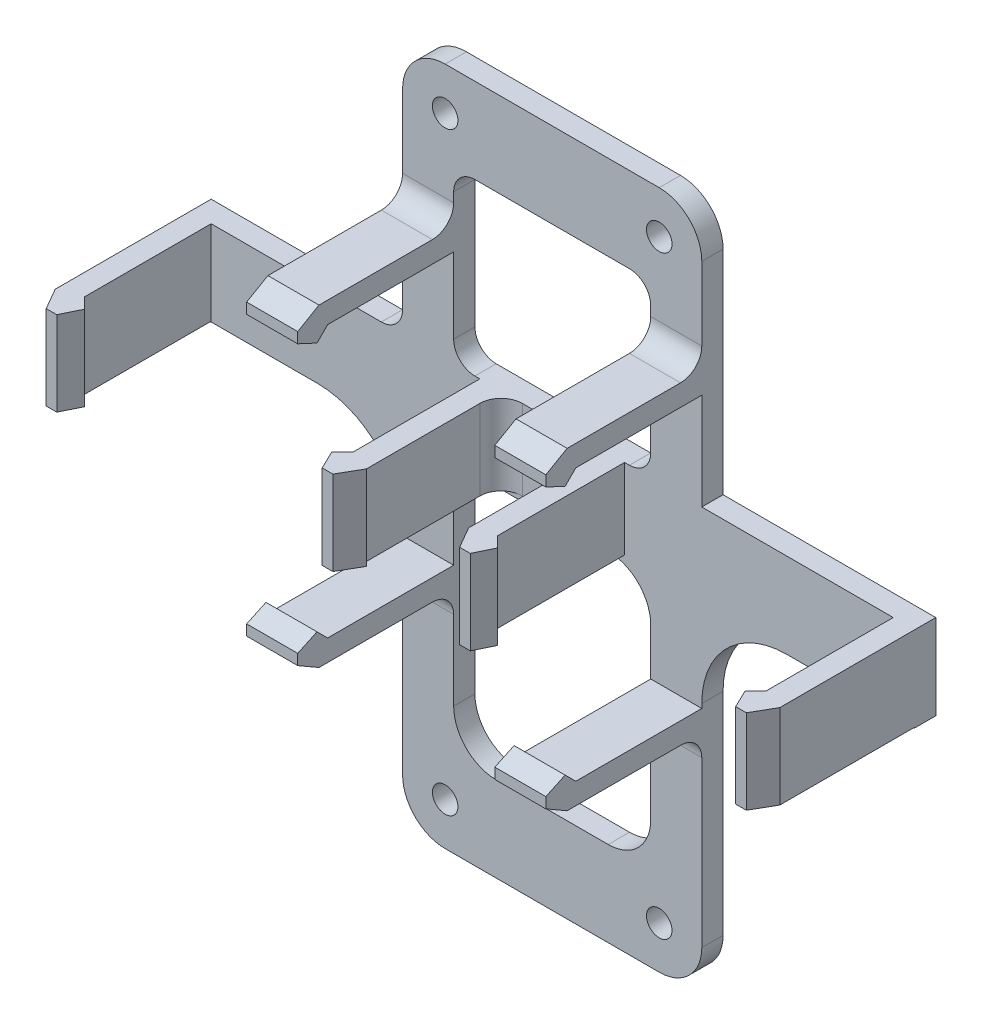
from build123d import *

# Parameters (mm, degrees)
SKETCH1_R           = 1.905
SKETCH1_W           = 29.4132
SKETCH1_H           = 25.4
BOSS_EXTRUDE1_DEPTH = 3.175
SKETCH2_W           = 3.175
SKETCH2_H           = 12.603189316
SKETCH2_H_2         = 11.966378631
SKETCH2_W_2         = 7.62
SKETCH2_H_3         = 3.175
BOSS_EXTRUDE2_DEPTH = 20.1
BOSS_EXTRUDE3_DEPTH = 12.603189
BOSS_EXTRUDE4_DEPTH = 7.62
FILLET1_R           = 6.35
FILLET2_R           = 3.175


with BuildPart() as part:
    # Sketch1 → Boss-Extrude1 (new body)
    with BuildSketch(Plane.XY):
        with BuildLine():
            Line((87.122, 101.406378631), (99.822, 101.406378631))
            Line((99.822, 101.406378631), (119.0752, 101.406378631))
            Line((119.0752, 101.406378631), (131.7752, 101.406378631))
            Line((131.7752, 101.406378631), (131.7752, 63.306378631))
            Line((131.7752, 63.306378631), (163.5252, 63.306378631))
            Line((163.5252, 63.306378631), (163.5252, 50.606378631))
            Line((163.5252, 50.606378631), (144.4752, 50.606378631))
            ThreePointArc((144.4752, 50.606378631), (135.494943879, 46.886634752), (131.7752, 37.906378631))
            Line((131.7752, 37.906378631), (131.7752, 6.35))
            ThreePointArc((131.7752, 6.35), (129.915328061, 1.859871939), (125.4252, 0))
            Line((125.4252, 0), (109.4486, 0))
            Line((109.4486, 0), (93.472, 0))
            ThreePointArc((93.472, 0), (88.981871939, 1.859871939), (87.122, 6.35))
            Line((87.122, 6.35), (87.122, 37.906378631))
            ThreePointArc((87.122, 37.906378631), (83.402256121, 46.886634752), (74.422, 50.606378631))
            Line((74.422, 50.606378631), (55.372, 50.606378631))
            Line((55.372, 50.606378631), (55.372, 63.306378631))
            Line((55.372, 63.306378631), (87.122, 63.306378631))
            Line((87.122, 63.306378631), (87.122, 101.406378631))
        make_face()
        with Locations((93.472, 95.056378631)):
            Circle(SKETCH1_R, mode=Mode.SUBTRACT)
        with Locations((125.4252, 95.056378631)):
            Circle(SKETCH1_R, mode=Mode.SUBTRACT)
        with Locations((93.472, 6.35)):
            Circle(SKETCH1_R, mode=Mode.SUBTRACT)
        with Locations((125.4252, 6.35)):
            Circle(SKETCH1_R, mode=Mode.SUBTRACT)
        with Locations((109.4486, 76.006378631)):
            Rectangle(SKETCH1_W, SKETCH1_H, mode=Mode.SUBTRACT)
        with BuildLine():
            Line((101.092, 50.606378631), (117.8052, 50.606378631))
            ThreePointArc((117.8052, 50.606378631), (122.295328061, 48.746506691), (124.1552, 44.256378631))
            Line((124.1552, 44.256378631), (124.1552, 19.05))
            ThreePointArc((124.1552, 19.05), (122.295328061, 14.559871939), (117.8052, 12.7))
            Line((117.8052, 12.7), (101.092, 12.7))
            ThreePointArc((101.092, 12.7), (96.601871939, 14.559871939), (94.742, 19.05))
            Line((94.742, 19.05), (94.742, 44.256378631))
            ThreePointArc((94.742, 44.256378631), (96.601871939, 48.746506691), (101.092, 50.606378631))
        make_face(mode=Mode.SUBTRACT)
    extrude(amount=BOSS_EXTRUDE1_DEPTH)

    # Sketch2 → Boss-Extrude2 (add)
    with BuildSketch(Plane.XY.offset(3.175)):
        with Locations((56.9595, 57.004783973)):
            Rectangle(SKETCH2_W, SKETCH2_H)
        with Locations((100.2345, 57.323189316)):
            Rectangle(SKETCH2_W, SKETCH2_H_2)
        with Locations((90.932, 35.6775)):
            Rectangle(SKETCH2_W_2, SKETCH2_H_3)
        with Locations((90.932, 79.3525)):
            Rectangle(SKETCH2_W_2, SKETCH2_H_3)
    boss_extrude2 = extrude(amount=BOSS_EXTRUDE2_DEPTH)

    # Sketch3 → Boss-Extrude3 (add)
    with BuildSketch(Plane(origin=(0, 63.306378631, 0), x_dir=(1, 0, 0), z_dir=(0, 1, 0))):
        Polygon((58.547, -22.103427125), (60.1345, -23.690927125), (58.792587105, -26.45), (57.205087105, -26.45), (55.372, -23.275), (58.547, -23.275), align=None)
        Polygon((98.647, -22.103427125), (97.0595, -23.690927125), (98.401412895, -26.45), (99.988912895, -26.45), (101.822, -23.275), (98.647, -23.275), align=None)
    boss_extrude3 = extrude(amount=-BOSS_EXTRUDE3_DEPTH)

    # Sketch4 → Boss-Extrude4 (add)
    with BuildSketch(Plane.ZY.offset(-87.122)):
        Polygon((23.275, 80.94), (23.275, 77.765), (21.982106781, 77.765), (23.569606781, 76.1775), (26.45, 77.519412895), (26.45, 79.106912895), align=None)
        Polygon((26.45, 35.923087105), (23.275, 34.09), (23.275, 37.265), (21.982106781, 37.265), (23.569606781, 38.8525), (26.45, 37.510587105), align=None)
    boss_extrude4 = extrude(amount=-BOSS_EXTRUDE4_DEPTH)

    # Fillet1
    fillet1_edges = [part.edges().sort_by_distance(p)[0] for p in [
        (87.122, 101.406378631, 1.5875),
        (131.7752, 101.406378631, 1.5875),
    ]]
    fillet(fillet1_edges, radius=FILLET1_R)

    # Mirror3: Boss-Extrude2, Boss-Extrude3, Boss-Extrude4 across plane
    add(boss_extrude2.mirror(Plane.ZY.offset(-109.4486)))
    add(boss_extrude3.mirror(Plane.ZY.offset(-109.4486)))
    add(boss_extrude4.mirror(Plane.ZY.offset(-109.4486)))

    # Fillet2
    fillet2_edges = [part.edges().sort_by_distance(p)[0] for p in [
        (101.822, 57.323189315, 3.175),
        (90.932, 34.09, 3.175),
        (90.932, 80.94, 3.175),
        (117.0752, 57.323189315, 3.175),
        (127.9652, 34.09, 3.175),
        (127.9652, 80.94, 3.175),
        (87.122, 63.306378631, 1.5875),
        (94.742, 63.306378631, 1.5875),
        (124.1552, 63.306378631, 1.5875),
        (124.1552, 88.706378631, 1.5875),
        (94.742, 88.706378631, 1.5875),
    ]]
    fillet(fillet2_edges, radius=FILLET2_R)


solid = part.part
